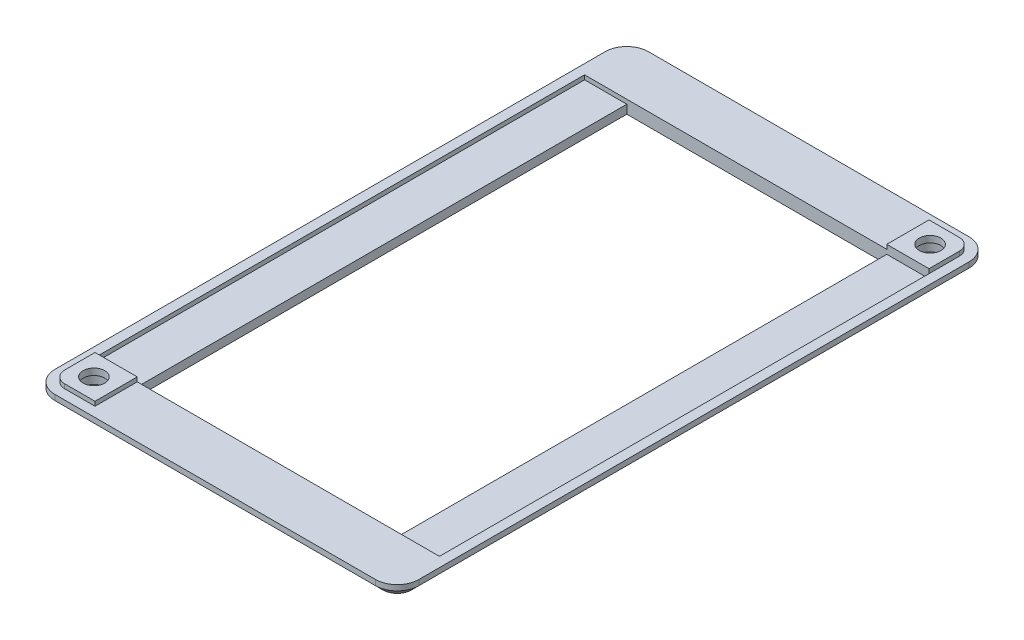
from build123d import *

# Parameters (mm, degrees)
SKETCH1_W           = 84
SKETCH1_H           = 137
BOSS_EXTRUDE1_DEPTH = 3
BOSS_EXTRUDE2_DEPTH = 1
FILLET1_R           = 5
SKETCH4_R           = 2.5
CUT_EXTRUDE1_DEPTH  = 5
SKETCH5_R           = 3.5
CUT_EXTRUDE2_DEPTH  = 3.5
SKETCH6_W           = 60
SKETCH6_H           = 113
CUT_EXTRUDE3_DEPTH  = 4
SKETCH7_W           = 79.5
SKETCH7_H           = 113
CUT_EXTRUDE4_DEPTH  = 1
CHAMFER1_SIZE       = 1.75


with BuildPart() as part:
    # Sketch1 → Boss-Extrude1 (new body)
    with BuildSketch(Plane(origin=(0, 0, 0), x_dir=(1, 0, 0), z_dir=(0, 1, 0))):
        with Locations((42, 68.5)):
            Rectangle(SKETCH1_W, SKETCH1_H)
    extrude(amount=BOSS_EXTRUDE1_DEPTH)

    # Sketch3 → Boss-Extrude2 (add)
    with BuildSketch(Plane(origin=(0, 3, 0), x_dir=(1, 0, 0), z_dir=(0, 1, 0))):
        with BuildLine():
            Line((81.75, 125), (72, 125))
            Line((72, 125), (72, 134.75))
            Line((72, 134.75), (79, 134.75))
            ThreePointArc((79, 134.75), (80.944543648, 133.944543648), (81.75, 132))
            Line((81.75, 132), (81.75, 125))
        make_face()
        with BuildLine():
            Line((12, 2.25), (12, 12))
            Line((12, 12), (2.25, 12))
            Line((2.25, 12), (2.25, 5))
            ThreePointArc((2.25, 5), (3.055456352, 3.055456352), (5, 2.25))
            Line((5, 2.25), (12, 2.25))
        make_face()
    extrude(amount=BOSS_EXTRUDE2_DEPTH)

    # Fillet1
    fillet1_edges = [part.edges().sort_by_distance(p)[0] for p in [
        (0, 1.5, -137),
        (84, 1.5, -137),
        (84, 1.5, 0),
        (0, 1.5, 0),
    ]]
    fillet(fillet1_edges, radius=FILLET1_R)

    # Sketch4 → Cut-Extrude1 (cut, through all)
    with BuildSketch(Plane(origin=(0, 4, 0), x_dir=(1, 0, 0), z_dir=(0, 1, 0))):
        with Locations((7, 7)):
            Circle(SKETCH4_R)
        with Locations((77, 130)):
            Circle(SKETCH4_R)
    extrude(amount=-CUT_EXTRUDE1_DEPTH, mode=Mode.SUBTRACT)

    # Sketch5 → Cut-Extrude2 (cut, through all)
    with BuildSketch(Plane(origin=(0, 2.5, 0), x_dir=(1, 0, 0), z_dir=(0, 1, 0))):
        with Locations((7, 7)):
            Circle(SKETCH5_R)
        with Locations((77, 130)):
            Circle(SKETCH5_R)
    extrude(amount=-CUT_EXTRUDE2_DEPTH, mode=Mode.SUBTRACT)

    # Sketch6 → Cut-Extrude3 (cut, through all)
    with BuildSketch(Plane(origin=(0, 3, 0), x_dir=(1, 0, 0), z_dir=(0, 1, 0))):
        with Locations((42, 68.5)):
            Rectangle(SKETCH6_W, SKETCH6_H)
    extrude(amount=-CUT_EXTRUDE3_DEPTH, mode=Mode.SUBTRACT)

    # Sketch7 → Cut-Extrude4 (cut)
    with BuildSketch(Plane(origin=(0, 3, 0), x_dir=(1, 0, 0), z_dir=(0, 1, 0))):
        with Locations((42, 68.5)):
            Rectangle(SKETCH7_W, SKETCH7_H)
    extrude(amount=-CUT_EXTRUDE4_DEPTH, mode=Mode.SUBTRACT)

    # Chamfer1
    chamfer1_edges = [part.edges().sort_by_distance(p)[0] for p in [
        (84, 0, -68.5),
        (0, 0, -68.5),
        (42, 0, -137),
        (42, 0, 0),
        (82.535533906, 0, -135.535533906),
        (1.464466094, 0, -135.535533906),
        (1.464466094, 0, -1.464466094),
        (82.535533906, 0, -1.464466094),
    ]]
    chamfer(chamfer1_edges, length=CHAMFER1_SIZE)


solid = part.part
